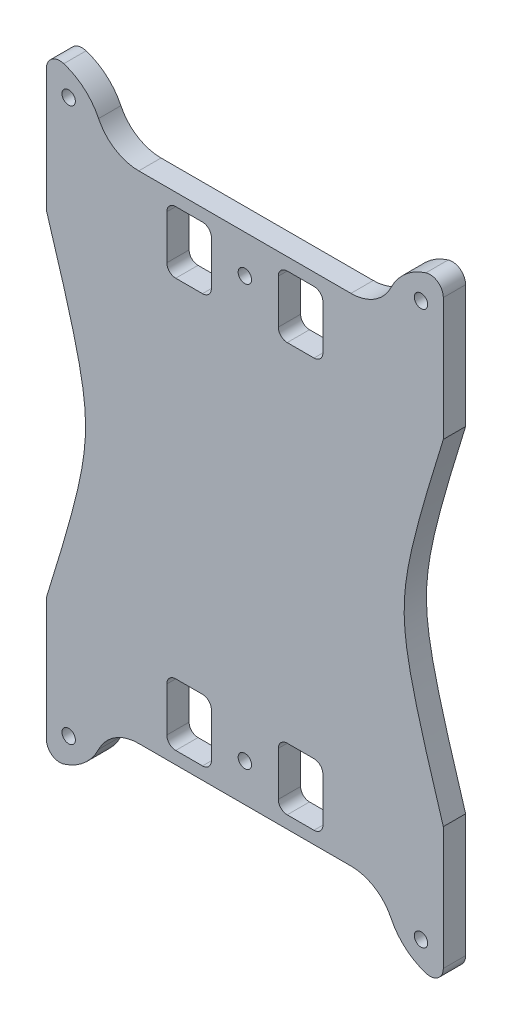
from build123d import *

# Parameters (mm, degrees)
RESSALTO_EXTRUS_O3_DEPTH = 5
ESBO_O4_R                = 1.5
CORTE_EXTRUS_O3_DEPTH    = 10


with BuildPart() as part:
    # Esboço1 → Ressalto-extrusão3 (new body)
    with BuildSketch(Plane.XY):
        with BuildLine():
            Line((-31.851570772, -17.801096987), (-27.063885949, -17.801096987))
            Line((-27.063885949, -17.801096987), (10.936114051, -17.801096987))
            Line((10.936114051, -17.801096987), (15.723798874, -17.801096987))
            ThreePointArc((15.723798874, -17.801096987), (21.039894205, -19.331201448), (24.729153299, -23.4532709))
            ThreePointArc((24.729153299, -23.4532709), (27.934250919, -27.635644423), (32.536114051, -30.202306605))
            ThreePointArc((32.536114051, -30.202306605), (35.210937986, -29.759166326), (36.436114051, -27.340489001))
            Line((36.436114051, -27.340489001), (36.436114051, -17.801096987))
            Line((36.436114051, -17.801096987), (36.436114051, 0.198903013))
            add(Edge.make_bspline(
                [(36.436114051, 75.398903013), (24.729153299, 37.798903013), (36.436114051, 0.198903013)],
                knots=[0, 0, 0, 1, 1, 1], degree=2, weights=[1, 3, 1]))
            Line((36.436114051, 75.398903013), (36.436114051, 93.398903013))
            Line((36.436114051, 93.398903013), (36.436114051, 102.938295027))
            ThreePointArc((36.436114051, 102.938295027), (35.210937986, 105.356972352), (32.536114051, 105.800112631))
            ThreePointArc((32.536114051, 105.800112631), (27.934250919, 103.23345045), (24.729153299, 99.051076926))
            ThreePointArc((24.729153299, 99.051076926), (21.039894205, 94.929007474), (15.723798874, 93.398903013))
            Line((15.723798874, 93.398903013), (10.936114051, 93.398903013))
            Line((10.936114051, 93.398903013), (-27.063885949, 93.398903013))
            Line((-27.063885949, 93.398903013), (-31.851570772, 93.398903013))
            ThreePointArc((-31.851570772, 93.398903013), (-37.167666102, 94.929007474), (-40.856925197, 99.051076926))
            ThreePointArc((-40.856925197, 99.051076926), (-44.062022817, 103.23345045), (-48.663885949, 105.800112631))
            ThreePointArc((-48.663885949, 105.800112631), (-51.338709884, 105.356972352), (-52.563885949, 102.938295027))
            Line((-52.563885949, 102.938295027), (-52.563885949, 93.398903013))
            Line((-52.563885949, 93.398903013), (-52.563885949, 75.398903013))
            add(Edge.make_bspline(
                [(-52.563885949, 75.398903013), (-40.856925197, 37.798903013), (-52.563885949, 0.198903013)],
                knots=[0, 0, 0, 1, 1, 1], degree=2, weights=[1, 3, 1]))
            Line((-52.563885949, 0.198903013), (-52.563885949, -17.801096987))
            Line((-52.563885949, -17.801096987), (-52.563885949, -27.340489001))
            ThreePointArc((-52.563885949, -27.340489001), (-51.338709884, -29.759166326), (-48.663885949, -30.202306605))
            ThreePointArc((-48.663885949, -30.202306605), (-44.062022817, -27.635644423), (-40.856925197, -23.4532709))
            ThreePointArc((-40.856925197, -23.4532709), (-37.167666102, -19.331201448), (-31.851570772, -17.801096987))
        make_face()
    extrude(amount=RESSALTO_EXTRUS_O3_DEPTH)

    # Esboço4 → Corte-extrusão3 (cut)
    with BuildSketch(Plane(origin=(0, 0, 0), x_dir=(-1, 0, 0), z_dir=(0, 0, -1))):
        with Locations((-31.436114051, 99.800112631)):
            Circle(ESBO_O4_R)
        with Locations((47.563885949, 99.800112631)):
            Circle(ESBO_O4_R)
        with Locations((8.063885949, 84.898903013)):
            Circle(ESBO_O4_R)
        with Locations((8.063885949, -9.301096987)):
            Circle(ESBO_O4_R)
        with Locations((47.563885949, -24.202306605)):
            Circle(ESBO_O4_R)
        with Locations((-31.436114051, -24.202306605)):
            Circle(ESBO_O4_R)
        with BuildLine():
            Line((-7.436114051, 90.598903013), (-1.436114051, 90.598903013))
            ThreePointArc((-1.436114051, 90.598903013), (-0.021900489, 90.013116575), (0.563885949, 88.598903013))
            Line((0.563885949, 88.598903013), (0.563885949, 78.698903013))
            ThreePointArc((0.563885949, 78.698903013), (-0.021900489, 77.284689451), (-1.436114051, 76.698903013))
            Line((-1.436114051, 76.698903013), (-7.436114051, 76.698903013))
            ThreePointArc((-7.436114051, 76.698903013), (-8.850327613, 77.284689451), (-9.436114051, 78.698903013))
            Line((-9.436114051, 78.698903013), (-9.436114051, 88.598903013))
            ThreePointArc((-9.436114051, 88.598903013), (-8.850327613, 90.013116575), (-7.436114051, 90.598903013))
        make_face()
        with BuildLine():
            Line((17.563885949, 90.598903013), (23.563885949, 90.598903013))
            ThreePointArc((23.563885949, 90.598903013), (24.978099511, 90.013116575), (25.563885949, 88.598903013))
            Line((25.563885949, 88.598903013), (25.563885949, 78.698903013))
            ThreePointArc((25.563885949, 78.698903013), (24.978099511, 77.284689451), (23.563885949, 76.698903013))
            Line((23.563885949, 76.698903013), (17.563885949, 76.698903013))
            ThreePointArc((17.563885949, 76.698903013), (16.149672387, 77.284689451), (15.563885949, 78.698903013))
            Line((15.563885949, 78.698903013), (15.563885949, 88.598903013))
            ThreePointArc((15.563885949, 88.598903013), (16.149672387, 90.013116575), (17.563885949, 90.598903013))
        make_face()
        with BuildLine():
            Line((25.563885949, -13.001096987), (25.563885949, -3.101096987))
            ThreePointArc((25.563885949, -3.101096987), (24.978099511, -1.686883425), (23.563885949, -1.101096987))
            Line((23.563885949, -1.101096987), (17.563885949, -1.101096987))
            ThreePointArc((17.563885949, -1.101096987), (16.149672387, -1.686883425), (15.563885949, -3.101096987))
            Line((15.563885949, -3.101096987), (15.563885949, -13.001096987))
            ThreePointArc((15.563885949, -13.001096987), (16.149672387, -14.415310549), (17.563885949, -15.001096987))
            Line((17.563885949, -15.001096987), (23.563885949, -15.001096987))
            ThreePointArc((23.563885949, -15.001096987), (24.978099511, -14.415310549), (25.563885949, -13.001096987))
        make_face()
        with BuildLine():
            Line((0.563885949, -13.001096987), (0.563885949, -3.101096987))
            ThreePointArc((0.563885949, -3.101096987), (-0.021900489, -1.686883425), (-1.436114051, -1.101096987))
            Line((-1.436114051, -1.101096987), (-7.436114051, -1.101096987))
            ThreePointArc((-7.436114051, -1.101096987), (-8.850327613, -1.686883425), (-9.436114051, -3.101096987))
            Line((-9.436114051, -3.101096987), (-9.436114051, -13.001096987))
            ThreePointArc((-9.436114051, -13.001096987), (-8.850327613, -14.415310549), (-7.436114051, -15.001096987))
            Line((-7.436114051, -15.001096987), (-1.436114051, -15.001096987))
            ThreePointArc((-1.436114051, -15.001096987), (-0.021900489, -14.415310549), (0.563885949, -13.001096987))
        make_face()
    extrude(amount=-CORTE_EXTRUS_O3_DEPTH, mode=Mode.SUBTRACT)


solid = part.part
